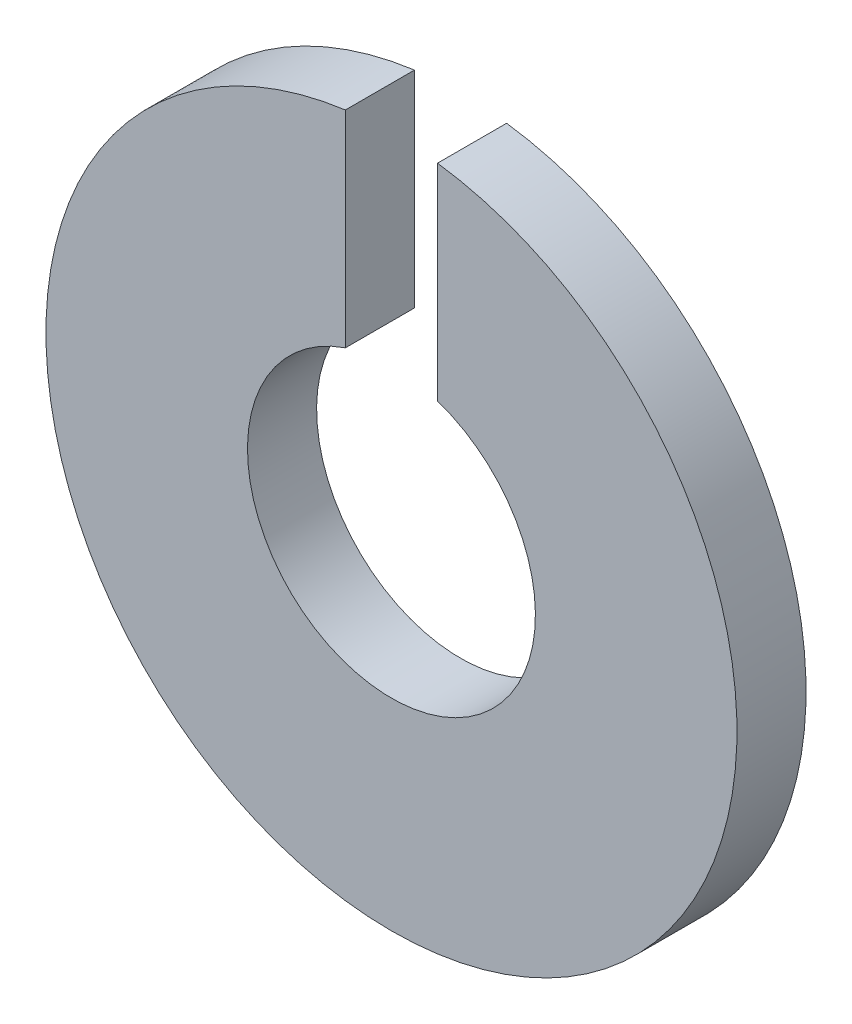
from build123d import *

# Parameters (mm, degrees)
SKETCH1_R               = 30
SKETCH1_R_2             = 12.5
BOSS_EXTRUDE1_DEPTH     = 6
CUT_EXTRUDE1_DEPTH      = 43.848570571
CUT_EXTRUDE1_DEPTH_BACK = 43.848570571
SKETCH2_W               = 8
SKETCH2_H               = 40


with BuildPart() as part:
    # Sketch1 → Boss-Extrude1 (new body)
    with BuildSketch(Plane.XY):
        Circle(SKETCH1_R)
        Circle(SKETCH1_R_2, mode=Mode.SUBTRACT)
    extrude(amount=BOSS_EXTRUDE1_DEPTH)

    # Sketch2 → Cut-Extrude1 (cut, two sides: drawn at the far end of the back side and taken through both)
    with BuildSketch(Plane.XY.offset(6).offset(-CUT_EXTRUDE1_DEPTH_BACK)):
        with Locations((0, 20)):
            Rectangle(SKETCH2_W, SKETCH2_H)
    extrude(amount=CUT_EXTRUDE1_DEPTH + CUT_EXTRUDE1_DEPTH_BACK, mode=Mode.SUBTRACT)


solid = part.part
